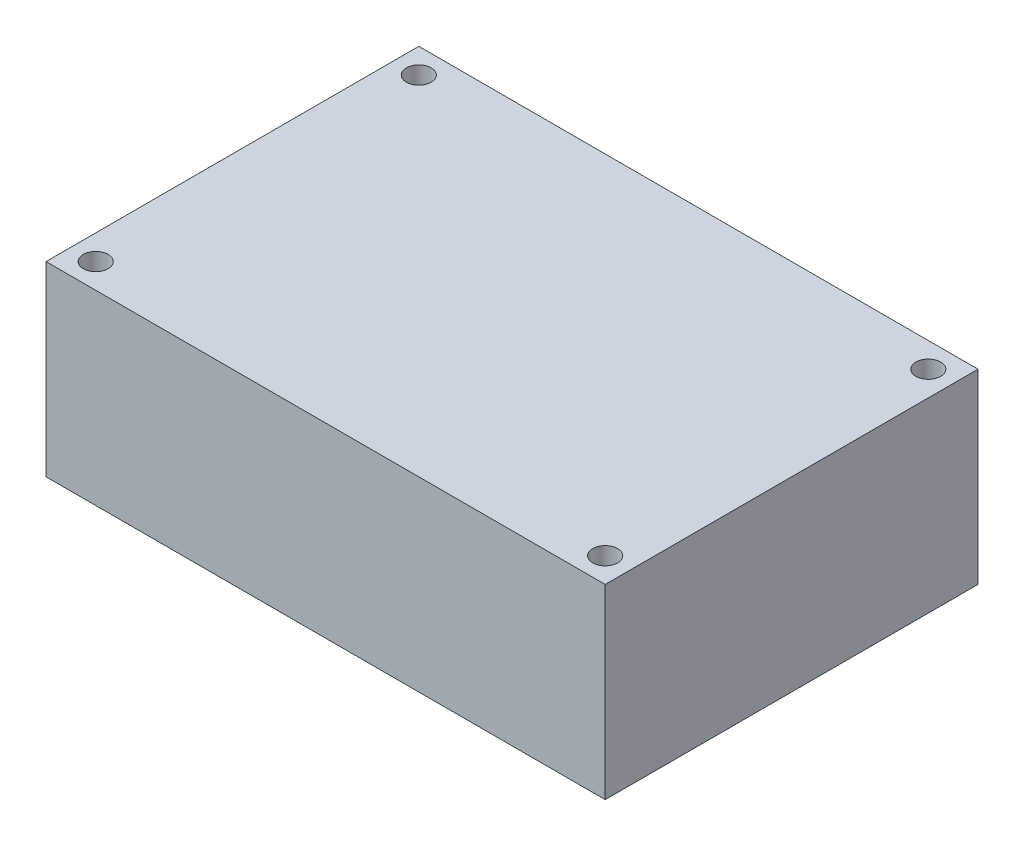
from build123d import *

# Parameters (mm, degrees)
SKETCH1_W           = 45
SKETCH1_H           = 30
SKETCH1_R           = 1
BOSS_EXTRUDE1_DEPTH = 15


with BuildPart() as part:
    # Sketch1 → Boss-Extrude1 (new body)
    with BuildSketch(Plane(origin=(0, 0, 0), x_dir=(1, 0, 0), z_dir=(0, 1, 0))):
        with Locations((-22.5, -15)):
            Rectangle(SKETCH1_W, SKETCH1_H)
        with Locations((-43, -2)):
            Circle(SKETCH1_R, mode=Mode.SUBTRACT)
        with Locations((-2, -2)):
            Circle(SKETCH1_R, mode=Mode.SUBTRACT)
        with Locations((-43, -28)):
            Circle(SKETCH1_R, mode=Mode.SUBTRACT)
        with Locations((-2, -28)):
            Circle(SKETCH1_R, mode=Mode.SUBTRACT)
    extrude(amount=BOSS_EXTRUDE1_DEPTH)


solid = part.part
